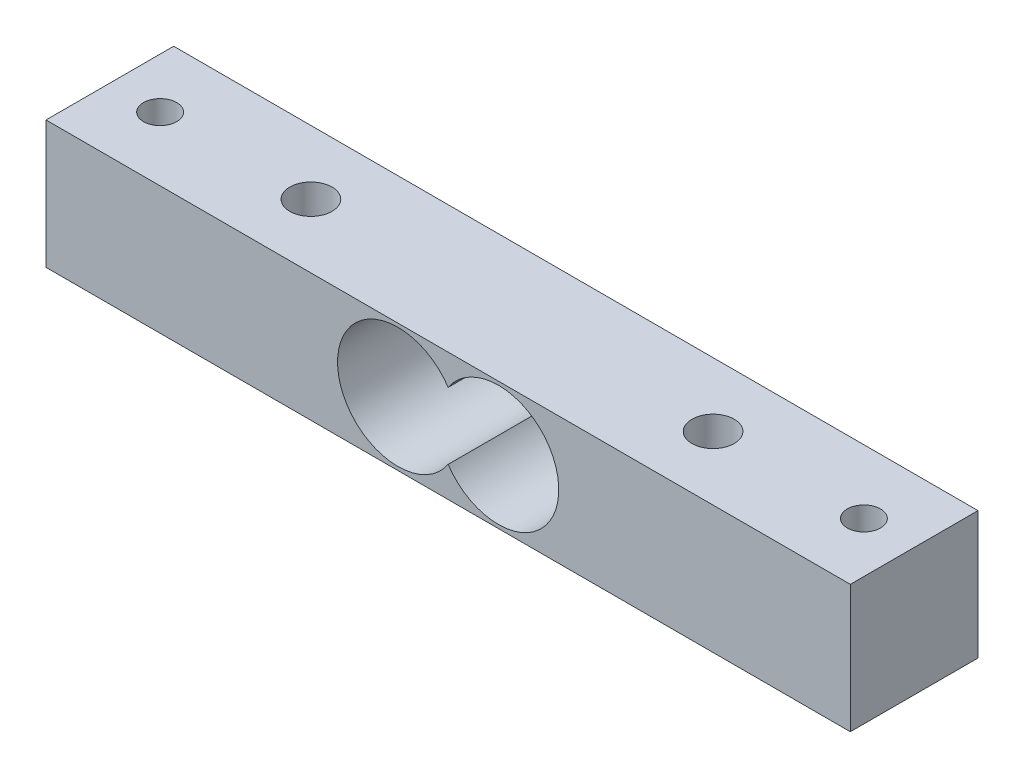
from build123d import *

# Parameters (mm, degrees)
SKETCH1_W                 = 80
SKETCH1_H                 = 12.7
BOSS_EXTRUDE1_DEPTH       = 6.35
SKETCH2_R                 = 6
CUT_EXTRUDE1_DEPTH        = 13.7
M4X0_7_TAPPED_HOLE2_D     = 3.3
M4X0_7_TAPPED_HOLE2_DEPTH = 12.7
M5X0_8_TAPPED_HOLE2_D     = 4.2
M5X0_8_TAPPED_HOLE2_DEPTH = 12.7


with BuildPart() as part:
    # Sketch1 → Boss-Extrude1 (new body, symmetric)
    with BuildSketch(Plane(origin=(0, 0, 0), x_dir=(1, 0, 0), z_dir=(0, 1, 0))):
        Rectangle(SKETCH1_W, SKETCH1_H)
    extrude(amount=BOSS_EXTRUDE1_DEPTH, both=True)

    # Sketch2 → Cut-Extrude1 (cut, through all)
    with BuildSketch(Plane.XY.offset(6.35)):
        with Locations((-5, 0)):
            Circle(SKETCH2_R)
        with Locations((5, 0)):
            Circle(SKETCH2_R)
    extrude(amount=-CUT_EXTRUDE1_DEPTH, mode=Mode.SUBTRACT)

    # M4x0.7 Tapped Hole2
    with Locations(Plane(origin=(0, 6.35, 0), x_dir=(1, 0, 0), z_dir=(0, 1, 0))):
        with Locations((-35, 0), (35, 0)):
            Hole(M4X0_7_TAPPED_HOLE2_D / 2, depth=M4X0_7_TAPPED_HOLE2_DEPTH)

    # M5x0.8 Tapped Hole2
    with Locations(Plane(origin=(0, 6.35, 0), x_dir=(1, 0, 0), z_dir=(0, 1, 0))):
        with Locations((20, 0), (-20, 0)):
            Hole(M5X0_8_TAPPED_HOLE2_D / 2, depth=M5X0_8_TAPPED_HOLE2_DEPTH)


solid = part.part
